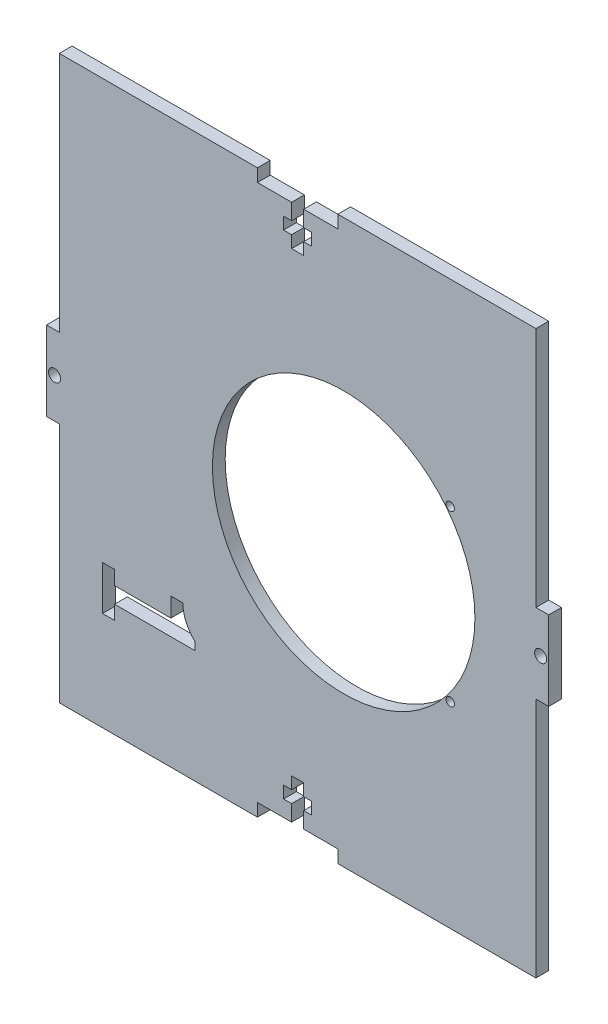
from build123d import *

# Parameters (mm, degrees)
SKETCH1_W           = 125
SKETCH1_H           = 140
BOSS_EXTRUDE1_DEPTH = 3.18
SKETCH2_R           = 1.5
SKETCH2_W           = 3.18
SKETCH2_H           = 60.125
CUT_EXTRUDE1_DEPTH  = 4.18
CUT_EXTRUDE5_DEPTH  = 12
SKETCH5_R           = 32.671394307
CUT_EXTRUDE6_DEPTH  = 10
SKETCH9_R           = 1.042012373
CUT_EXTRUDE8_DEPTH  = 4.18


with BuildPart() as part:
    # Sketch1 → Boss-Extrude1 (new body)
    with BuildSketch(Plane.XY):
        Rectangle(SKETCH1_W, SKETCH1_H)
    extrude(amount=BOSS_EXTRUDE1_DEPTH)

    # Sketch2 → Cut-Extrude1 (cut, through all)
    with BuildSketch(Plane.XY.offset(3.18)):
        with Locations((-60.5, 0)):
            Circle(SKETCH2_R)
        with Locations((60.5, 0)):
            Circle(SKETCH2_R)
        Polygon((-10, 70), (10, 70), (10, 66.82), (1.5, 66.82), (1.5, 62.82), (3.5, 62.82), (3.5, 59.82), (1.5, 59.82), (1.5, 56.82), (-1.5, 56.82), (-1.5, 59.82), (-3.5, 59.82), (-3.5, 62.82), (-1.5, 62.82), (-1.5, 66.82), (-10, 66.82), align=None)
        Polygon((-10, -70), (-10, -66.82), (-1.5, -66.82), (-1.5, -62.82), (-3.5, -62.82), (-3.5, -59.82), (-1.5, -59.82), (-1.5, -56.82), (1.5, -56.82), (1.5, -59.82), (3.5, -59.82), (3.5, -62.82), (1.5, -62.82), (1.5, -66.82), (10, -66.82), (10, -70), align=None)
        with Locations((-60.91, 39.9375)):
            Rectangle(SKETCH2_W, SKETCH2_H)
        with Locations((-60.91, -39.9375)):
            Rectangle(SKETCH2_W, SKETCH2_H)
        with Locations((60.91, -39.9375)):
            Rectangle(SKETCH2_W, SKETCH2_H)
        with Locations((60.91, 39.9375)):
            Rectangle(SKETCH2_W, SKETCH2_H)
    extrude(amount=-CUT_EXTRUDE1_DEPTH, mode=Mode.SUBTRACT)

    # Sketch4 → Cut-Extrude5 (cut)
    with BuildSketch(Plane.XY):
        with BuildLine():
            Line((-25.57107609, -41.8625), (-45.57107609, -41.8625))
            Line((-45.57107609, -41.8625), (-45.57107609, -45.3625))
            Line((-45.57107609, -45.3625), (-48.57107609, -45.3625))
            Line((-48.57107609, -45.3625), (-48.57107609, -34.3625))
            Line((-48.57107609, -34.3625), (-45.57107609, -34.3625))
            Line((-45.57107609, -34.3625), (-45.57107609, -37.8625))
            Line((-45.57107609, -37.8625), (-31.57107609, -37.8625))
            Line((-31.57107609, -37.8625), (-31.57107609, -33.087601989))
            Line((-31.57107609, -33.087601989), (-28.57107609, -33.087601989))
            ThreePointArc((-28.57107609, -33.087601989), (-27.787526444, -36.79230316), (-25.57107609, -39.8625))
            Line((-25.57107609, -39.8625), (-25.57107609, -41.8625))
        make_face()
    extrude(amount=CUT_EXTRUDE5_DEPTH, mode=Mode.SUBTRACT)

    # Sketch5 → Cut-Extrude6 (cut)
    with BuildSketch(Plane.XY.offset(3.18)):
        with Locations((11.462576996, 0)):
            Circle(SKETCH5_R)
    extrude(amount=-CUT_EXTRUDE6_DEPTH, mode=Mode.SUBTRACT)

    # Sketch9 → Cut-Extrude8 (cut, through all)
    with BuildSketch(Plane.XY.offset(3.18)):
        with Locations((37.991387583, -21.1)):
            Circle(SKETCH9_R)
        with Locations((37.991387583, 21.008299604)):
            Circle(SKETCH9_R)
    extrude(amount=-CUT_EXTRUDE8_DEPTH, mode=Mode.SUBTRACT)


solid = part.part
